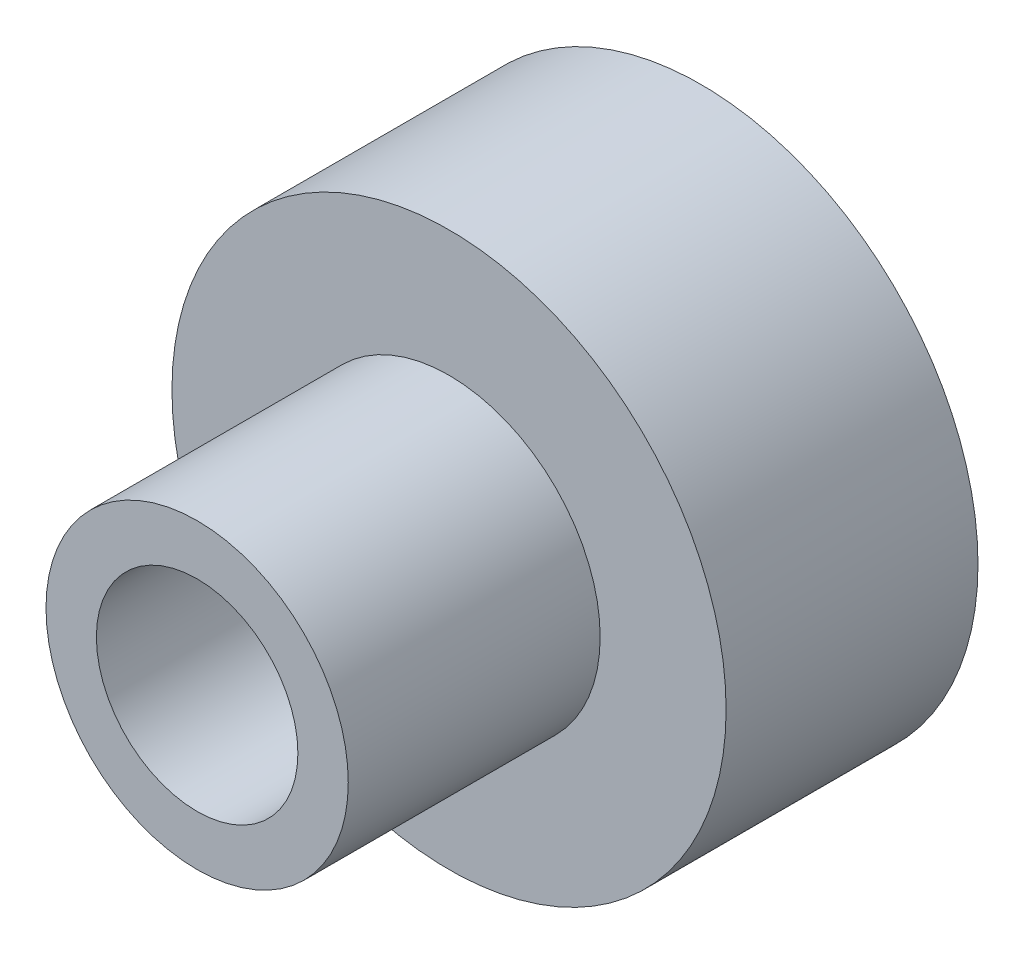
from build123d import *

# Parameters (mm, degrees)
SKETCH1_R           = 30
BOSS_EXTRUDE1_DEPTH = 50
SKETCH1_4_R         = 55
SKETCH1_4_R_2       = 30
BOSS_EXTRUDE2_DEPTH = 50
SKETCH2_R           = 20
CUT_EXTRUDE1_DEPTH  = 127.688594593
SKETCH3_R           = 42.5
CUT_EXTRUDE2_DEPTH  = 40


with BuildPart() as part:
    # Sketch1 → Boss-Extrude1 (new body)
    with BuildSketch(Plane.XY):
        Circle(SKETCH1_R)
    extrude(amount=BOSS_EXTRUDE1_DEPTH)

    # Sketch2 → Cut-Extrude1 (cut, through all)
    with BuildSketch(Plane.XY.offset(50)):
        Circle(SKETCH2_R)
    extrude(amount=-CUT_EXTRUDE1_DEPTH, mode=Mode.SUBTRACT)


with BuildPart() as body_2:
    # Sketch1_4 → Boss-Extrude2 (new body)
    with BuildSketch(Plane.XY):
        Circle(SKETCH1_4_R)
        Circle(SKETCH1_4_R_2, mode=Mode.SUBTRACT)
    extrude(amount=-BOSS_EXTRUDE2_DEPTH)

    # Sketch3 → Cut-Extrude2 (cut)
    with BuildSketch(Plane(origin=(0, 0, -50), x_dir=(-1, 0, 0), z_dir=(0, 0, -1))):
        Circle(SKETCH3_R)
    extrude(amount=-CUT_EXTRUDE2_DEPTH, mode=Mode.SUBTRACT)


solid = Compound([part.part, body_2.part])
